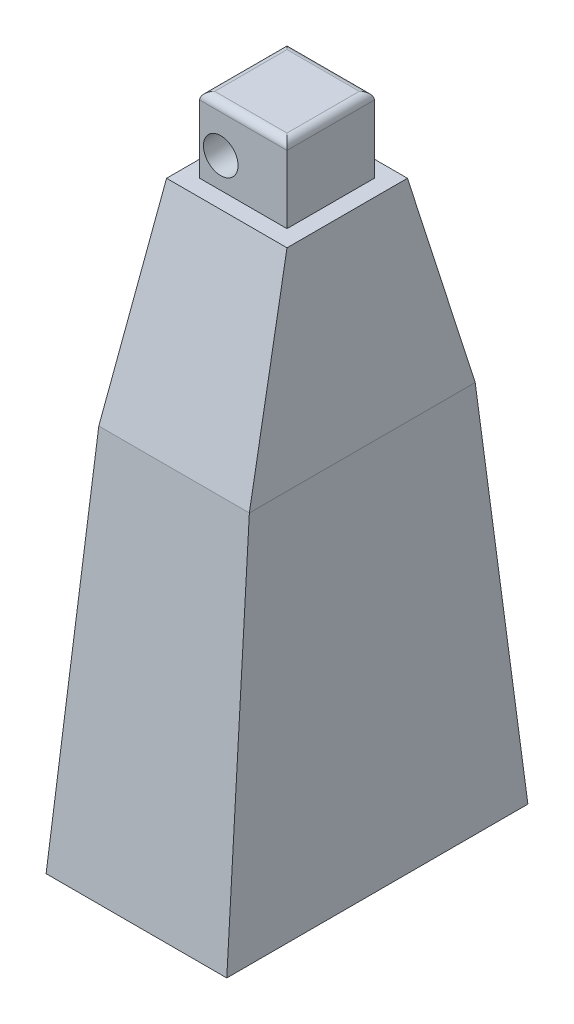
from build123d import *

# Parameters (mm, degrees)
SKETCH1_W           = 24
SKETCH1_H           = 40
SKETCH2_W           = 20
SKETCH2_H           = 30
SKETCH3_W           = 20
SKETCH3_H           = 30
SKETCH4_W           = 16
SKETCH4_H           = 16
SKETCH5_W           = 11.6
SKETCH5_H           = 11.6
BOSS_EXTRUDE1_DEPTH = 10
SKETCH6_R           = 2.3
CUT_EXTRUDE1_DEPTH  = 6
SKETCH7_R           = 2.3
CUT_EXTRUDE2_DEPTH  = 6
FILLET1_R           = 1
SKETCH8_W           = 8.4
SKETCH8_H           = 24.4
CUT_EXTRUDE3_DEPTH  = 20
SKETCH9_R           = 2.3
CUT_EXTRUDE4_DEPTH  = 6


with BuildPart() as part:
    # Sketch1 → Loft1 section 0
    with BuildSketch(Plane(origin=(0, 0, 0), x_dir=(1, 0, 0), z_dir=(0, 1, 0))):
        Rectangle(SKETCH1_W, SKETCH1_H)
    # Sketch2 → Loft1 section 1
    with BuildSketch(Plane(origin=(0, 50, 0), x_dir=(1, 0, 0), z_dir=(0, 1, 0))):
        Rectangle(SKETCH2_W, SKETCH2_H)
    loft()

    # Sketch3 → Loft2 section 0
    with BuildSketch(Plane(origin=(0, 50, 0), x_dir=(1, 0, 0), z_dir=(0, 1, 0))):
        Rectangle(SKETCH3_W, SKETCH3_H)
    # Sketch4 → Loft2 section 1
    with BuildSketch(Plane(origin=(0, 76, 0), x_dir=(1, 0, 0), z_dir=(0, 1, 0))):
        Rectangle(SKETCH4_W, SKETCH4_H)
    loft()

    # Sketch5 → Boss-Extrude1 (add)
    with BuildSketch(Plane(origin=(0, 76, 0), x_dir=(1, 0, 0), z_dir=(0, 1, 0))):
        Rectangle(SKETCH5_W, SKETCH5_H)
    extrude(amount=BOSS_EXTRUDE1_DEPTH)

    # Sketch6 → Cut-Extrude1 (cut)
    with BuildSketch(Plane.XY.offset(5.8)):
        with Locations((-3, 80)):
            Circle(SKETCH6_R)
    extrude(amount=-CUT_EXTRUDE1_DEPTH, mode=Mode.SUBTRACT)

    # Sketch7 → Cut-Extrude2 (cut)
    with BuildSketch(Plane(origin=(0, 0, -5.8), x_dir=(-1, 0, 0), z_dir=(0, 0, -1))):
        with Locations((-3, 80)):
            Circle(SKETCH7_R)
    extrude(amount=-CUT_EXTRUDE2_DEPTH, mode=Mode.SUBTRACT)

    # Fillet1
    fillet1_edges = [part.edges().sort_by_distance(p)[0] for p in [
        (0, 86, 5.8),
        (5.8, 86, 0),
        (0, 86, -5.8),
        (-5.8, 86, 0),
    ]]
    fillet(fillet1_edges, radius=FILLET1_R)

    # Sketch8 → Cut-Extrude3 (cut)
    with BuildSketch(Plane.XZ):
        Rectangle(SKETCH8_W, SKETCH8_H)
    extrude(amount=-CUT_EXTRUDE3_DEPTH, mode=Mode.SUBTRACT)

    # Sketch9 → Cut-Extrude4 (cut)
    with BuildSketch(Plane.XZ):
        with Locations((0, 16)):
            Circle(SKETCH9_R)
        with Locations((0, -16)):
            Circle(SKETCH9_R)
    extrude(amount=-CUT_EXTRUDE4_DEPTH, mode=Mode.SUBTRACT)


solid = part.part
